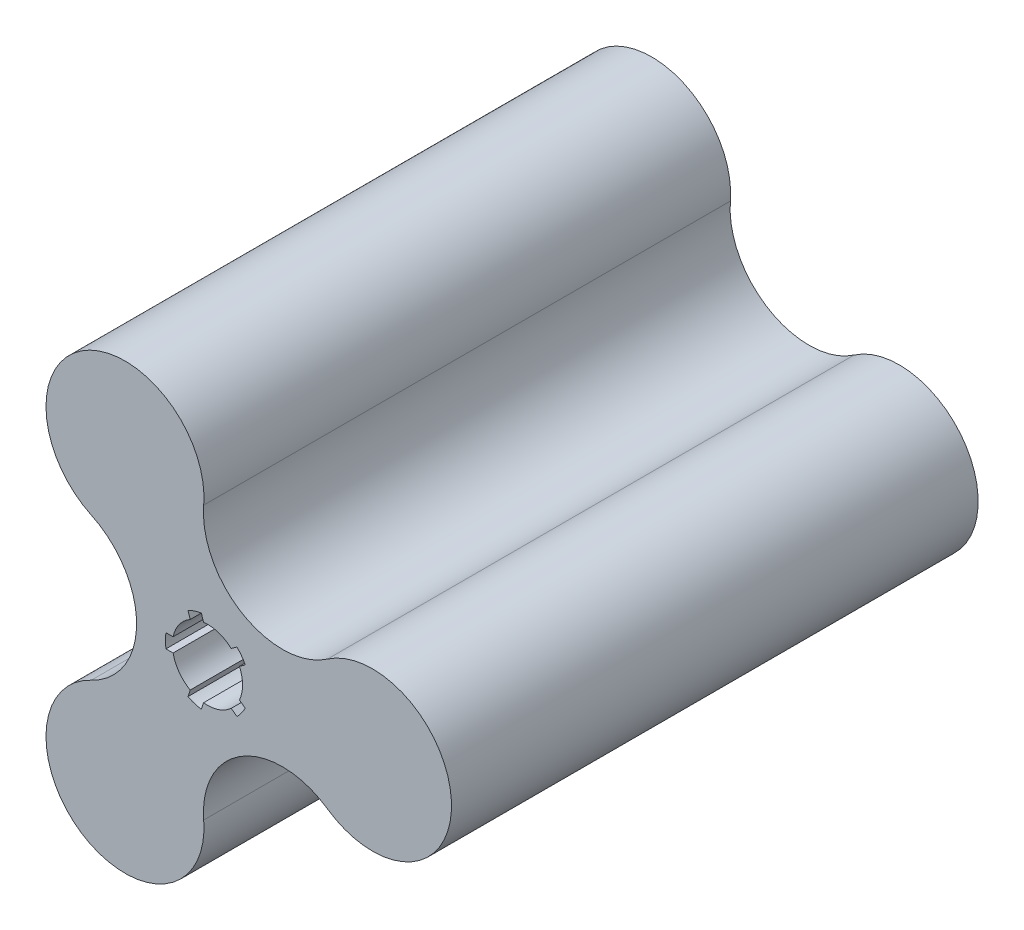
from build123d import *

# Parameters (mm, degrees)
Y_KSEKLIK_EKSTR_ZYON1_DEPTH = 150


with BuildPart() as part:
    # Çizim1 → Yükseklik-Ekstrüzyon1 (new body)
    with BuildSketch(Plane.XY):
        with BuildLine():
            ThreePointArc((-1.077539734, -38.836840411), (10.094920531, -17.484915258), (34.172460266, -18.485243422))
            ThreePointArc((34.172460266, -18.485243422), (69.5, 0), (34.172460266, 18.485243422))
            ThreePointArc((34.172460266, 18.485243422), (10.094920531, 17.484915258), (-1.077539734, 38.836840411))
            ThreePointArc((-1.077539734, 38.836840411), (-34.75, 60.188765563), (-33.094920531, 20.351596989))
            ThreePointArc((-33.094920531, 20.351596989), (-20.189841062, 0), (-33.094920531, -20.351596989))
            ThreePointArc((-33.094920531, -20.351596989), (-34.75, -60.188765563), (-1.077539734, -38.836840411))
        make_face()
        with BuildLine():
            ThreePointArc((-5.558451419, 10.635018469), (-3.708203932, 11.412678196), (-1.754225354, 11.871086446))
            Line((-1.754225354, 11.871086446), (-1.1256228, 9.936446715))
            ThreePointArc((-1.1256228, 9.936446715), (3.090169944, 9.510565163), (6.751144813, 7.377129775))
            Line((6.751144813, 7.377129775), (8.396847665, 8.572802885))
            ThreePointArc((8.396847665, 8.572802885), (9.708203932, 7.053423028), (10.747988674, 5.336734907))
            Line((10.747988674, 5.336734907), (9.102285822, 4.141061797))
            ThreePointArc((9.102285822, 4.141061797), (9.77299489, 2.118624763), (10, 0))
            ThreePointArc((10, 0), (9.77299489, -2.118624763), (9.102285822, -4.141061797))
            Line((9.102285822, -4.141061797), (10.747988674, -5.336734907))
            ThreePointArc((10.747988674, -5.336734907), (9.708203932, -7.053423028), (8.396847665, -8.572802885))
            Line((8.396847665, -8.572802885), (6.751144813, -7.377129775))
            ThreePointArc((6.751144813, -7.377129775), (3.090169944, -9.510565163), (-1.1256228, -9.936446715))
            Line((-1.1256228, -9.936446715), (-1.754225354, -11.871086446))
            ThreePointArc((-1.754225354, -11.871086446), (-3.708203932, -11.412678196), (-5.558451419, -10.635018469))
            Line((-5.558451419, -10.635018469), (-4.929848865, -8.700378737))
            ThreePointArc((-4.929848865, -8.700378737), (-8.090169944, -5.877852523), (-9.797958971, -2))
            Line((-9.797958971, -2), (-11.832159566, -2))
            ThreePointArc((-11.832159566, -2), (-12, 0), (-11.832159566, 2))
            Line((-11.832159566, 2), (-9.797958971, 2))
            ThreePointArc((-9.797958971, 2), (-8.090169944, 5.877852523), (-4.929848865, 8.700378737))
            Line((-4.929848865, 8.700378737), (-5.558451419, 10.635018469))
        make_face(mode=Mode.SUBTRACT)
    extrude(amount=-Y_KSEKLIK_EKSTR_ZYON1_DEPTH)


solid = part.part
